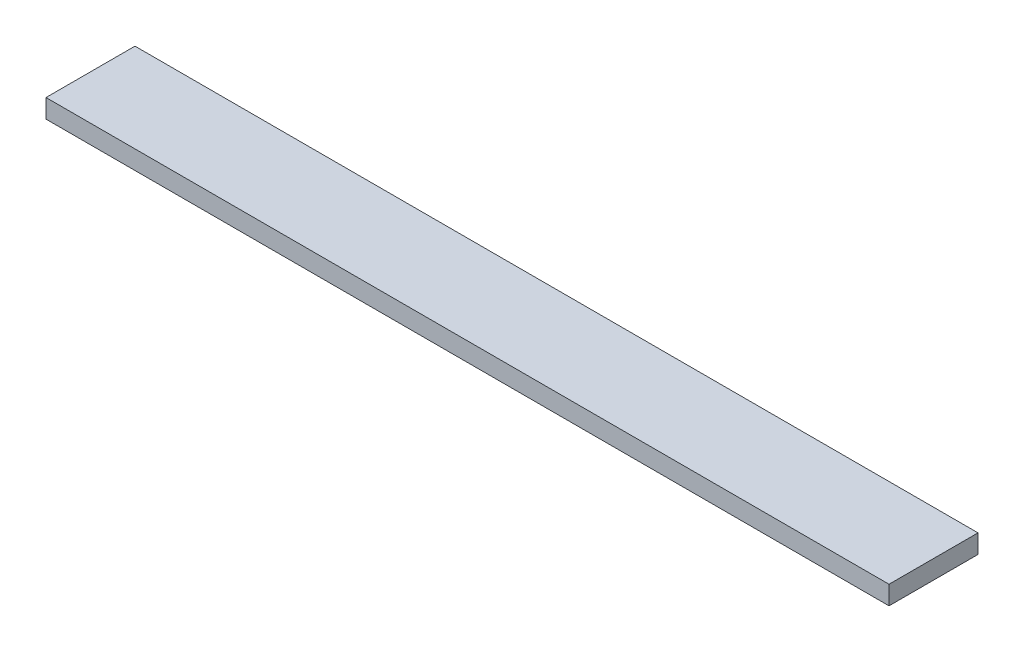
from build123d import *

# Parameters (mm, degrees)
SKETCH1_W           = 114.3
SKETCH1_H           = 12.065
BOSS_EXTRUDE1_DEPTH = 2.54


with BuildPart() as part:
    # Sketch1 → Boss-Extrude1 (new body)
    with BuildSketch(Plane(origin=(0, 0, 0), x_dir=(1, 0, 0), z_dir=(0, 1, 0))):
        with Locations((57.15, 6.0325)):
            Rectangle(SKETCH1_W, SKETCH1_H)
    extrude(amount=BOSS_EXTRUDE1_DEPTH)


solid = part.part
